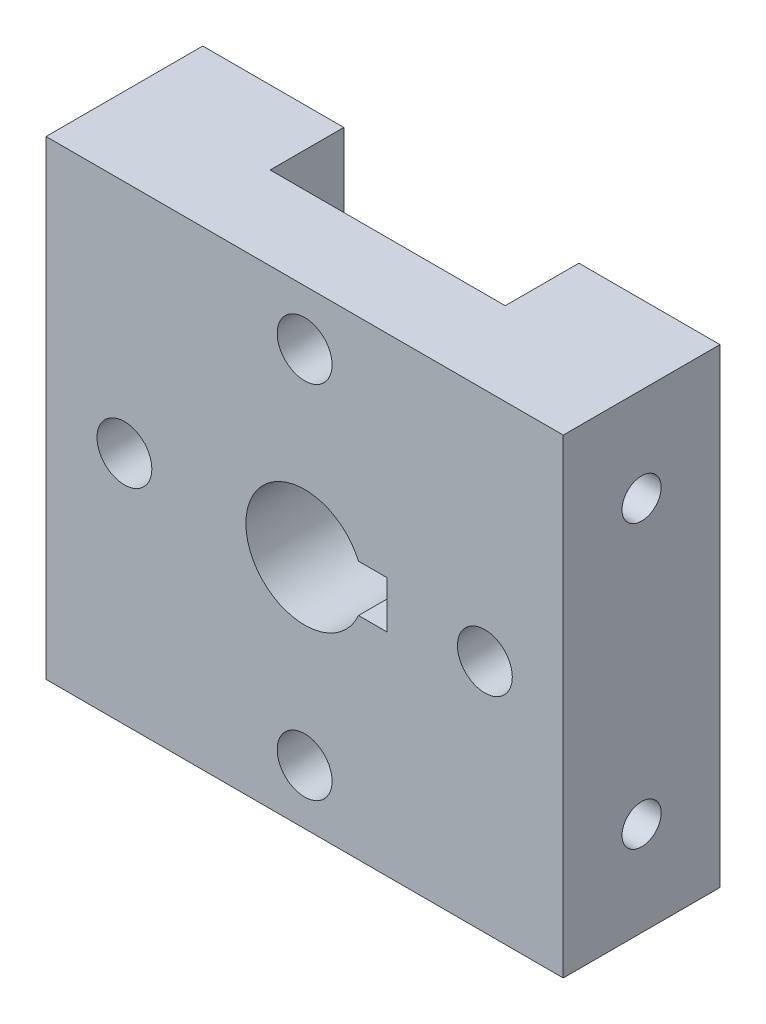
from build123d import *

# Parameters (mm, degrees)
SKETCH1_W                  = 66
SKETCH1_H                  = 60
BOSS_EXTRUDE1_DEPTH        = 20
CUT_EXTRUDE1_REACH         = 62
SKETCH2_W                  = 30
SKETCH2_H                  = 9.4
M6_TAPPED_HOLE1_AT_2_COUNT = 2
M6_TAPPED_HOLE1_AT_2_PITCH = 36
SKETCH7_R                  = 3.5
CUT_EXTRUDE2_DEPTH         = 21
SKETCH9_R                  = 6
CUT_EXTRUDE3_DEPTH         = 6


with BuildPart() as part:
    # Sketch1 → Boss-Extrude1 (new body)
    with BuildSketch(Plane.XY):
        Rectangle(SKETCH1_W, SKETCH1_H)
        with BuildLine():
            Line((10.5, -3), (6.873863542, -3))
            ThreePointArc((6.873863542, -3), (-7.5, 0), (6.873863542, 3))
            Line((6.873863542, 3), (10.5, 3))
            Line((10.5, 3), (10.5, -3))
        make_face(mode=Mode.SUBTRACT)
    extrude(amount=BOSS_EXTRUDE1_DEPTH)

    # Sketch2 → Cut-Extrude1 (cut, up to next)
    with BuildSketch(Plane(origin=(0, 30, 0), x_dir=(1, 0, 0), z_dir=(0, 1, 0)), mode=Mode.PRIVATE) as cut_extrude1_sk1:
        with Locations((0, -4.7)):
            Rectangle(SKETCH2_W, SKETCH2_H)
    cut_extrude1_tool1 = extrude(cut_extrude1_sk1.sketch, amount=-CUT_EXTRUDE1_REACH, mode=Mode.PRIVATE) & part.part
    add(cut_extrude1_tool1.solids().sort_by_distance((0, 30, 4.7))[0], mode=Mode.SUBTRACT)

    # Sketch5 → M6 Tapped Hole1 (revolve, cut)
    with BuildSketch(Plane(origin=(-33, 18, 10), x_dir=(0, 0, 1), z_dir=(0, 1, 0))):
        Polygon((0, 0), (0, 29.502151548), (2.5, 28), (2.5, 0), align=None)
    m6_tapped_hole1 = revolve(axis=Axis((-39.35, 18, 10), (1, 0, 0)), mode=Mode.SUBTRACT)

    # M6 Tapped Hole1 at 2: M6 Tapped Hole1 ×2
    with Locations(*[(0, -i * M6_TAPPED_HOLE1_AT_2_PITCH, 0) for i in range(1, M6_TAPPED_HOLE1_AT_2_COUNT)]):
        add(m6_tapped_hole1, mode=Mode.SUBTRACT)

    # Mirror1: M6 Tapped Hole1 across plane
    add(m6_tapped_hole1.mirror(Plane(origin=(0, 0, 0), x_dir=(0, 0, 1), z_dir=(1, 0, 0))), mode=Mode.SUBTRACT)

    # Mirror1 copy 1 sketch → Mirror1 copy 1 (revolve, cut)
    with BuildSketch(Plane(origin=(33, -18, 10), x_dir=(0, 0, 1), z_dir=(0, 1, 0))):
        Polygon((0, 0), (0, -29.502151548), (2.5, -28), (2.5, 0), align=None)
    revolve(axis=Axis((39.35, -18, 10), (1, 0, 0)), mode=Mode.SUBTRACT)

    # Sketch7 → Cut-Extrude2 (cut, through all)
    with BuildSketch(Plane.XY.offset(20)):
        with Locations((0, 23)):
            Circle(SKETCH7_R)
        with Locations((23, 0)):
            Circle(SKETCH7_R)
        with Locations((0, -23)):
            Circle(SKETCH7_R)
        with Locations((-23, 0)):
            Circle(SKETCH7_R)
    extrude(amount=-CUT_EXTRUDE2_DEPTH, mode=Mode.SUBTRACT)

    # Sketch9 → Cut-Extrude3 (cut)
    with BuildSketch(Plane(origin=(0, 0, 0), x_dir=(-1, 0, 0), z_dir=(0, 0, -1))):
        with Locations((23, 0)):
            Circle(SKETCH9_R)
        with Locations((-23, 0)):
            Circle(SKETCH9_R)
    extrude(amount=-CUT_EXTRUDE3_DEPTH, mode=Mode.SUBTRACT)


solid = part.part
